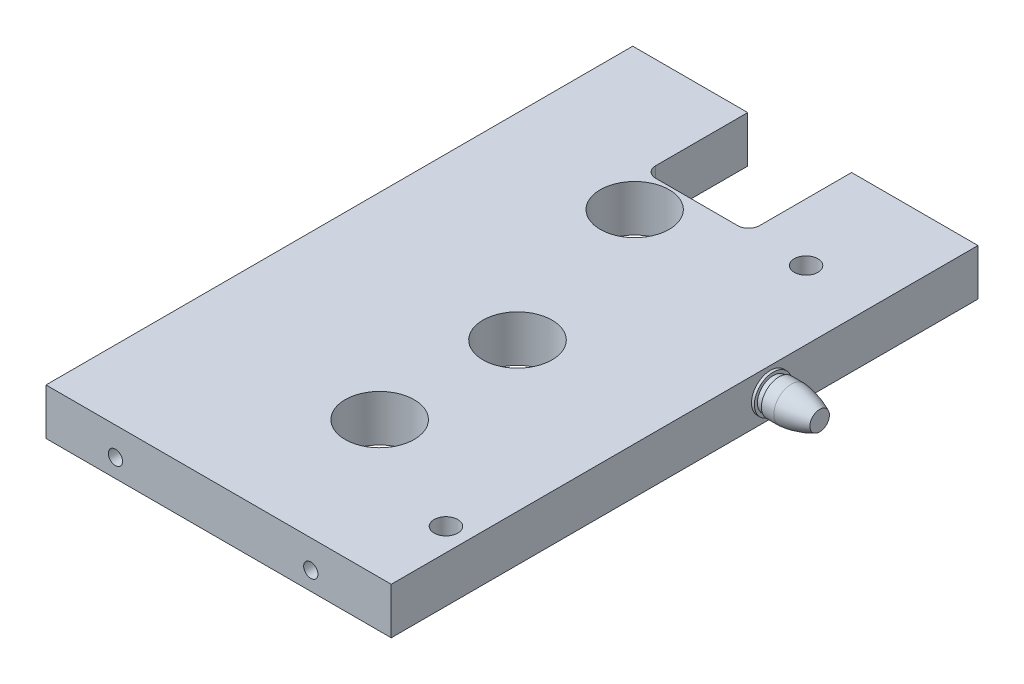
from build123d import *

# Parameters (mm, degrees)
SKETCH1_W           = 95.25
SKETCH1_H           = 12.8
BOSS_EXTRUDE1_DEPTH = 161.88
SKETCH1_3_R         = 3.1
CUT_EXTRUDE1_DEPTH  = 20.2
SKETCH1_4_R         = 2.395
CUT_EXTRUDE2_DEPTH  = 21.5
CUT_EXTRUDE3_REACH  = 14.8
SKETCH2_R           = 9.525
SKETCH2_R_2         = 3.265
SKETCH3_R           = 3.265
SKETCH3_R_2         = 9.525
CUT_EXTRUDE4_DEPTH  = 3.32
CUT_EXTRUDE5_START  = -17.25
SKETCH4_R           = 1.965
CUT_EXTRUDE5_DEPTH  = 17.25
SKETCH6_R           = 9.5
CUT_EXTRUDE6_DEPTH  = 13.8000001


with BuildPart() as part:
    # Sketch1 → Boss-Extrude1 (new body)
    with BuildSketch(Plane.XY):
        with Locations((-282.25, -82.5)):
            Rectangle(SKETCH1_W, SKETCH1_H)
    extrude(amount=BOSS_EXTRUDE1_DEPTH)

    # Sketch1_3 → Cut-Extrude1 (cut)
    with BuildSketch(Plane.XY):
        with Locations((-308, -82.5)):
            Circle(SKETCH1_3_R)
        with Locations((-257.2, -82.5)):
            Circle(SKETCH1_3_R)
    extrude(amount=CUT_EXTRUDE1_DEPTH, mode=Mode.SUBTRACT)

    # Sketch1_4 → Cut-Extrude2 (cut)
    with BuildSketch(Plane.XY):
        with Locations((-320.5, -82.5)):
            Circle(SKETCH1_4_R)
        with Locations((-244.2, -82.5)):
            Circle(SKETCH1_4_R)
    extrude(amount=CUT_EXTRUDE2_DEPTH, mode=Mode.SUBTRACT)

    # Sketch2 → Cut-Extrude3 (cut, up to next)
    with BuildSketch(Plane(origin=(0, -76.1, 0), x_dir=(-1, 0, 0), z_dir=(0, 1, 0)), mode=Mode.PRIVATE) as cut_extrude3_sk1:
        with Locations((275.57, 86.105)):
            Circle(SKETCH2_R)
    cut_extrude3_tool1 = extrude(cut_extrude3_sk1.sketch, amount=-CUT_EXTRUDE3_REACH, mode=Mode.PRIVATE) & part.part
    add(cut_extrude3_tool1.solids().sort_by_distance((-275.57, -76.1, 86.105))[0], mode=Mode.SUBTRACT)
    # Sketch2 → Cut-Extrude3 (cut, up to next)
    with BuildSketch(Plane(origin=(0, -76.1, 0), x_dir=(-1, 0, 0), z_dir=(0, 1, 0)), mode=Mode.PRIVATE) as cut_extrude3_sk2:
        with Locations((275.57, 124.135)):
            Circle(SKETCH2_R)
    cut_extrude3_tool2 = extrude(cut_extrude3_sk2.sketch, amount=-CUT_EXTRUDE3_REACH, mode=Mode.PRIVATE) & part.part
    add(cut_extrude3_tool2.solids().sort_by_distance((-275.57, -76.1, 124.135))[0], mode=Mode.SUBTRACT)
    # Sketch2 → Cut-Extrude3 (cut, up to next)
    with BuildSketch(Plane(origin=(0, -76.1, 0), x_dir=(-1, 0, 0), z_dir=(0, 1, 0)), mode=Mode.PRIVATE) as cut_extrude3_sk3:
        with Locations((253.55, 28.505)):
            Circle(SKETCH2_R_2)
    cut_extrude3_tool3 = extrude(cut_extrude3_sk3.sketch, amount=-CUT_EXTRUDE3_REACH, mode=Mode.PRIVATE) & part.part
    add(cut_extrude3_tool3.solids().sort_by_distance((-253.55, -76.1, 28.505))[0], mode=Mode.SUBTRACT)
    # Sketch2 → Cut-Extrude3 (cut, up to next)
    with BuildSketch(Plane(origin=(0, -76.1, 0), x_dir=(-1, 0, 0), z_dir=(0, 1, 0)), mode=Mode.PRIVATE) as cut_extrude3_sk4:
        with Locations((240.925, 140.49)):
            Circle(SKETCH2_R_2)
    cut_extrude3_tool4 = extrude(cut_extrude3_sk4.sketch, amount=-CUT_EXTRUDE3_REACH, mode=Mode.PRIVATE) & part.part
    add(cut_extrude3_tool4.solids().sort_by_distance((-240.925, -76.1, 140.49))[0], mode=Mode.SUBTRACT)
    # Sketch2 → Cut-Extrude3 (cut, up to next)
    with BuildSketch(Plane(origin=(0, -76.1, 0), x_dir=(-1, 0, 0), z_dir=(0, 1, 0)), mode=Mode.PRIVATE) as cut_extrude3_sk5:
        with BuildLine():
            Line((269.505, 25.4), (269.505, 0))
            Line((269.505, 0), (298.155, 0))
            Line((298.155, 0), (298.155, 25.4))
            ThreePointArc((298.155, 25.4), (297.276320344, 27.521320344), (295.155, 28.4))
            Line((295.155, 28.4), (272.505, 28.4))
            ThreePointArc((272.505, 28.4), (270.383679656, 27.521320344), (269.505, 25.4))
        make_face()
    cut_extrude3_tool5 = extrude(cut_extrude3_sk5.sketch, amount=-CUT_EXTRUDE3_REACH, mode=Mode.PRIVATE) & part.part
    add(cut_extrude3_tool5.solids().sort_by_distance((-283.83, -76.1, 14.135461))[0], mode=Mode.SUBTRACT)

    # Sketch3 → Cut-Extrude4 (cut)
    with BuildSketch(Plane.XZ.offset(88.9)):
        with Locations((-240.925, 140.49)):
            Circle(SKETCH3_R)
        with Locations((-253.55, 28.505)):
            Circle(SKETCH3_R_2)
    extrude(amount=-CUT_EXTRUDE4_DEPTH, mode=Mode.SUBTRACT)

    # Sketch4 → Cut-Extrude5 (cut)
    with BuildSketch(Plane.XY.offset(161.88).offset(CUT_EXTRUDE5_START)):
        with Locations((-256.825, -83.83)):
            Circle(SKETCH4_R)
        with Locations((-310.715, -83.83)):
            Circle(SKETCH4_R)
    extrude(amount=CUT_EXTRUDE5_DEPTH, mode=Mode.SUBTRACT)

    # Sketch5 → Revolve1 (revolve)
    with BuildSketch(Plane(origin=(0, -82.5, 0), x_dir=(-1, 0, 0), z_dir=(0, 1, 0))):
        with BuildLine():
            Line((234.625, 57.29), (221.025, 57.29))
            Line((221.025, 57.29), (221.025, 54.59))
            ThreePointArc((221.025, 54.59), (224.841543887, 53.18542762), (228.845807042, 52.475))
            Line((228.845807042, 52.475), (232.275807042, 52.475))
            Line((232.275807042, 52.475), (232.295, 52.925))
            Line((232.295, 52.925), (233.835, 52.925))
            Line((233.835, 52.925), (233.835, 52.09))
            Line((233.835, 52.09), (234.625, 52.09))
            Line((234.625, 52.09), (234.625, 57.29))
        make_face()
    revolve(axis=Axis((-234.625, -82.5, 57.29), (-1, 0, 0)))

    # Sketch6 → Cut-Extrude6 (cut, through all)
    with BuildSketch(Plane(origin=(0, -76.1, 0), x_dir=(-1, 0, 0), z_dir=(0, 1, 0))):
        with Locations((290.57, 38.77)):
            Circle(SKETCH6_R)
    extrude(amount=-CUT_EXTRUDE6_DEPTH, mode=Mode.SUBTRACT)


solid = part.part
